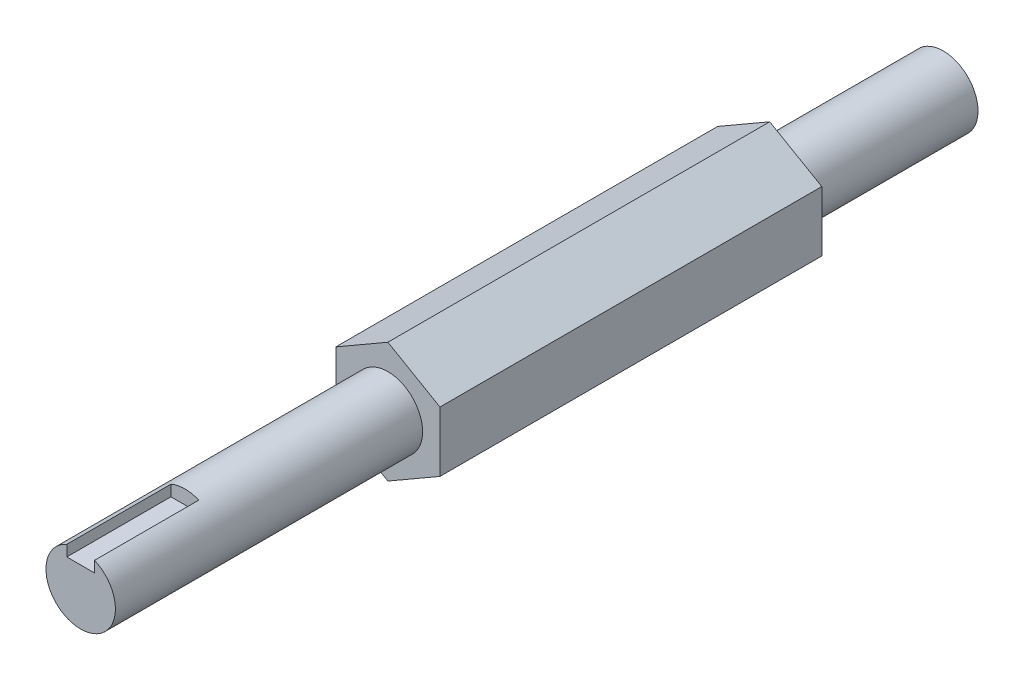
from build123d import *

# Parameters (mm, degrees)
RESSALTO_EXTRUS_O1_DEPTH = 110
ESBO_O2_R                = 10
RESSALTO_EXTRUS_O2_DEPTH = 88.5
ESBO_O3_R                = 10
RESSALTO_EXTRUS_O3_DEPTH = 50
ESBO_O5_W                = 8
ESBO_O5_H                = 8
CORTE_EXTRUS_O1_DEPTH    = 30


with BuildPart() as part:
    # Esboço1 → Ressalto-extrusão1 (new body)
    with BuildSketch(Plane.XY):
        Polygon((-15, 8.660254038), (-15, -8.660254038), (0, -17.320508076), (15, -8.660254038), (15, 8.660254038), (0, 17.320508076), align=None)
    extrude(amount=RESSALTO_EXTRUS_O1_DEPTH)

    # Esboço2 → Ressalto-extrusão2 (add)
    with BuildSketch(Plane.XY.offset(110)):
        Circle(ESBO_O2_R)
    extrude(amount=RESSALTO_EXTRUS_O2_DEPTH)

    # Esboço3 → Ressalto-extrusão3 (add)
    with BuildSketch(Plane(origin=(0, 0, 0), x_dir=(-1, 0, 0), z_dir=(0, 0, -1))):
        Circle(ESBO_O3_R)
    extrude(amount=RESSALTO_EXTRUS_O3_DEPTH)

    # Esboço5 → Corte-extrusão1 (cut)
    with BuildSketch(Plane.XY.offset(198.5)):
        with Locations((0, 10)):
            Rectangle(ESBO_O5_W, ESBO_O5_H)
    extrude(amount=-CORTE_EXTRUS_O1_DEPTH, mode=Mode.SUBTRACT)


solid = part.part
